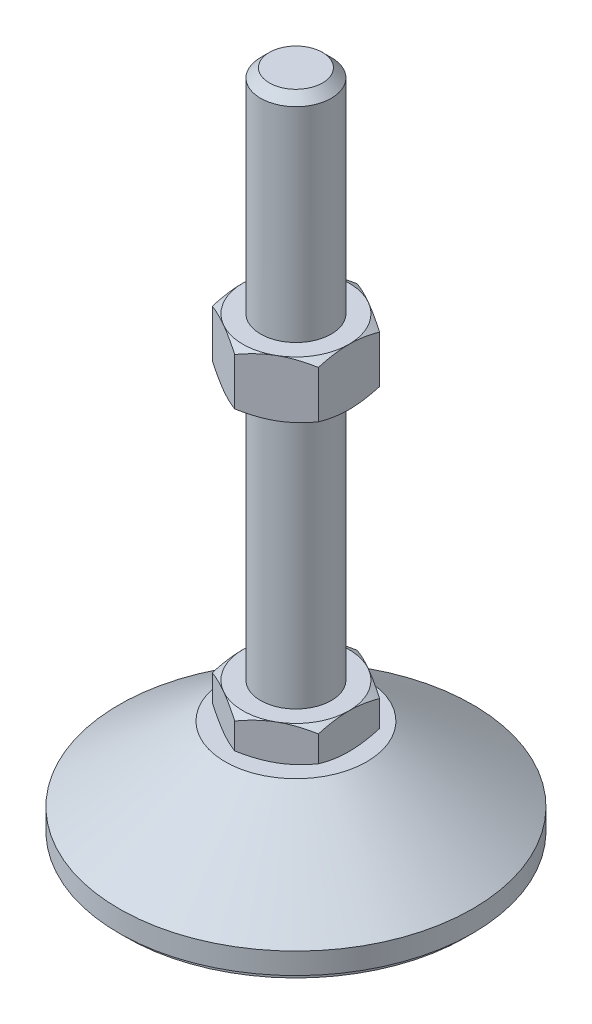
from build123d import *

# Parameters (mm, degrees)
EXTRUDE_1_DEPTH = 10
EXTRUDE_2_DEPTH = 16


with BuildPart() as part:
    # Эскиз1 → Повернуть1 (revolve)
    with BuildSketch(Plane.XY, mode=Mode.PRIVATE) as revolve_1_sk:
        Polygon((0, 0), (-48, 0), (-48, 2), (-50, 2), (-50, 8), (-20, 29), (-10, 29), (-10, 39), (-10, 186.5), (-7.5, 189), (0, 189), align=None)
    revolve(revolve_1_sk.sketch.rotate(Axis((0, 0, 0), (0, 1, 0)), 180), axis=Axis((0, 0, 0), (0, 1, 0)))  # turned: the seam where the file's is

    # Эскиз2 → Бобышка-Вытянуть1 (add)
    with BuildSketch(Plane(origin=(0, 29, 0), x_dir=(1, 0, 0), z_dir=(0, 1, 0))):
        Polygon((0, 17.320508076), (-15, 8.660254038), (-15, -8.660254038), (0, -17.320508076), (15, -8.660254038), (15, 8.660254038), align=None)
    extrude(amount=EXTRUDE_1_DEPTH)

    # Эскиз3 → Бобышка-Вытянуть2 (add)
    with BuildSketch(Plane(origin=(0, 112.75, 0), x_dir=(1, 0, 0), z_dir=(0, 1, 0))):
        Polygon((15, 8.660254038), (0, 17.320508076), (-15, 8.660254038), (-15, -8.660254038), (0, -17.320508076), (15, -8.660254038), align=None)
    extrude(amount=EXTRUDE_2_DEPTH)

    # Эскиз4 → Вырез-Повернуть2 (revolve, cut)
    with BuildSketch(Plane.XY, mode=Mode.PRIVATE) as cut_revolve_2_sk:
        Polygon((-28.856406461, 128.75), (-15, 128.75), (-28.856406461, 120.75), align=None)
        Polygon((-28.856406461, 112.75), (-28.856406461, 120.75), (-15, 112.75), align=None)
        Polygon((-23.660254038, 39), (-23.660254038, 34), (-15, 39), align=None)
        Polygon((-23.660254038, 34), (-23.660254038, 29), (-15, 29), align=None)
    revolve(cut_revolve_2_sk.sketch.rotate(Axis((0, 189, 0), (0, -1, 0)), 180), axis=Axis((0, 189, 0), (0, -1, 0)), mode=Mode.SUBTRACT)  # turned: the seam where the file's is


solid = part.part
